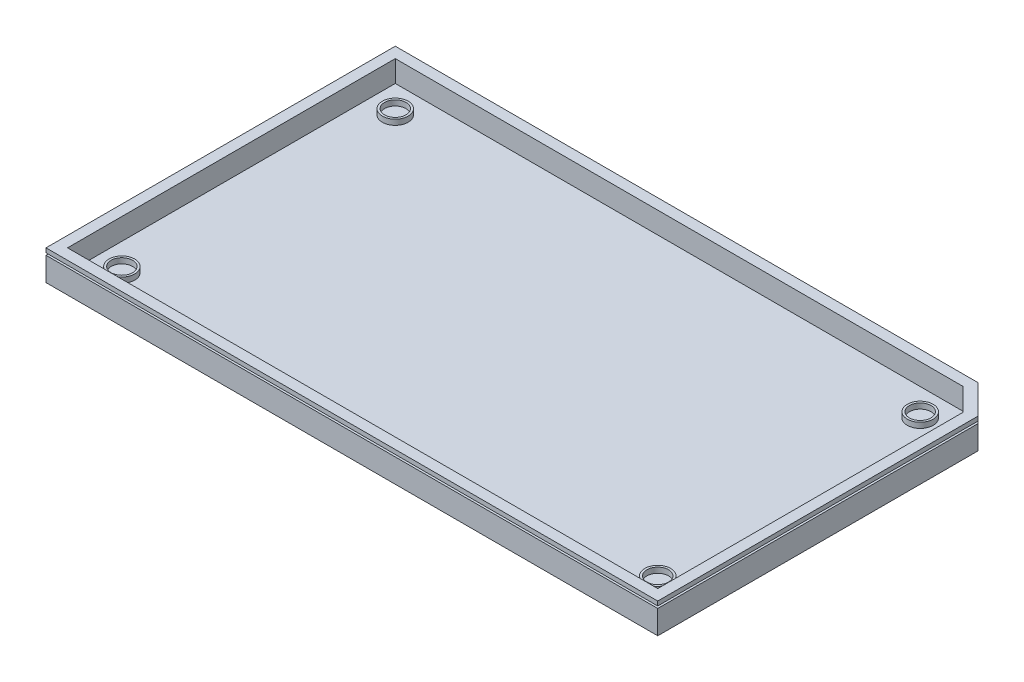
from build123d import *

# Parameters (mm, degrees)
BOSS_EXTRUDE1_DEPTH      = 5
BOSS_EXTRUDE1_DEPTH_BACK = 2
CUT_EXTRUDE1_DEPTH       = 5
SKETCH5_R                = 3
SKETCH5_R_2              = 2.5
BOSS_EXTRUDE2_DEPTH      = 1.25
BOSS_EXTRUDE2_2_DEPTH    = 1.25
BOSS_EXTRUDE2_3_DEPTH    = 1.25
BOSS_EXTRUDE2_4_DEPTH    = 1.25
CUT_EXTRUDE2_DEPTH       = 0.5


with BuildPart() as part:
    # Sketch3 → Boss-Extrude1 (new, two sides: drawn at the far end of the back side and taken through both)
    with BuildSketch(Plane(origin=(0, 0, 0), x_dir=(1, 0, 0), z_dir=(0, 1, 0)).offset(-BOSS_EXTRUDE1_DEPTH_BACK)):
        Polygon((72.945, 33.821067812), (66.206067812, 40.56), (-69.135, 40.56), (-69.135, -40.56), (72.945, -40.56), align=None)
    extrude(amount=BOSS_EXTRUDE1_DEPTH + BOSS_EXTRUDE1_DEPTH_BACK)

    # Sketch4 → Cut-Extrude1 (cut)
    with BuildSketch(Plane(origin=(0, 0, 0), x_dir=(1, 0, 0), z_dir=(0, 1, 0))):
        Polygon((-66.635, -38.06), (70.445, -38.06), (70.445, 32.785533906), (65.170533906, 38.06), (-66.635, 38.06), align=None)
    extrude(amount=CUT_EXTRUDE1_DEPTH, mode=Mode.SUBTRACT)

    # Sketch6 → Cut-Extrude2 (cut)
    with BuildSketch(Plane(origin=(0, 4, 0), x_dir=(1, 0, 0), z_dir=(0, 1, 0))):
        Polygon((-70.135, 41.56), (-70.135, -41.56), (73.945, -41.56), (73.945, 34.235281374), (66.620281374, 41.56), align=None)
        Polygon((-68.135, 39.56), (-68.135, -39.56), (71.945, -39.56), (71.945, 33.406854249), (65.791854249, 39.56), align=None, mode=Mode.SUBTRACT)
    extrude(amount=-CUT_EXTRUDE2_DEPTH, mode=Mode.SUBTRACT)


with BuildPart() as body_2:
    # Sketch5 → Boss-Extrude2 (new body)
    with BuildSketch(Plane(origin=(0, 0, 0), x_dir=(1, 0, 0), z_dir=(0, 1, 0))):
        with Locations(Location((-60.325, -31.75, 0), (0, 0, 270))):
            Circle(SKETCH5_R)
        with Locations(Location((-60.325, -31.75, 0), (0, 0, 270))):
            Circle(SKETCH5_R_2, mode=Mode.SUBTRACT)
    extrude(amount=BOSS_EXTRUDE2_DEPTH)


with BuildPart() as body_3:
    # Sketch5 → Boss-Extrude2 2 (new body)
    with BuildSketch(Plane(origin=(0, 0, 0), x_dir=(1, 0, 0), z_dir=(0, 1, 0))):
        with Locations(Location((-60.325, 31.75, 0), (0, 0, 270))):
            Circle(SKETCH5_R)
        with Locations(Location((-60.325, 31.75, 0), (0, 0, 270))):
            Circle(SKETCH5_R_2, mode=Mode.SUBTRACT)
    extrude(amount=BOSS_EXTRUDE2_2_DEPTH)


with BuildPart() as body_4:
    # Sketch5 → Boss-Extrude2 3 (new body)
    with BuildSketch(Plane(origin=(0, 0, 0), x_dir=(1, 0, 0), z_dir=(0, 1, 0))):
        with Locations(Location((61.595, 31.75, 0), (0, 0, 270))):
            Circle(SKETCH5_R)
        with Locations(Location((61.595, 31.75, 0), (0, 0, 270))):
            Circle(SKETCH5_R_2, mode=Mode.SUBTRACT)
    extrude(amount=BOSS_EXTRUDE2_3_DEPTH)


with BuildPart() as body_5:
    # Sketch5 → Boss-Extrude2 4 (new body)
    with BuildSketch(Plane(origin=(0, 0, 0), x_dir=(1, 0, 0), z_dir=(0, 1, 0))):
        with Locations(Location((64.135, -31.75, 0), (0, 0, 270))):
            Circle(SKETCH5_R)
        with Locations(Location((64.135, -31.75, 0), (0, 0, 270))):
            Circle(SKETCH5_R_2, mode=Mode.SUBTRACT)
    extrude(amount=BOSS_EXTRUDE2_4_DEPTH)


solid = Compound([part.part, body_2.part, body_3.part, body_4.part, body_5.part])
